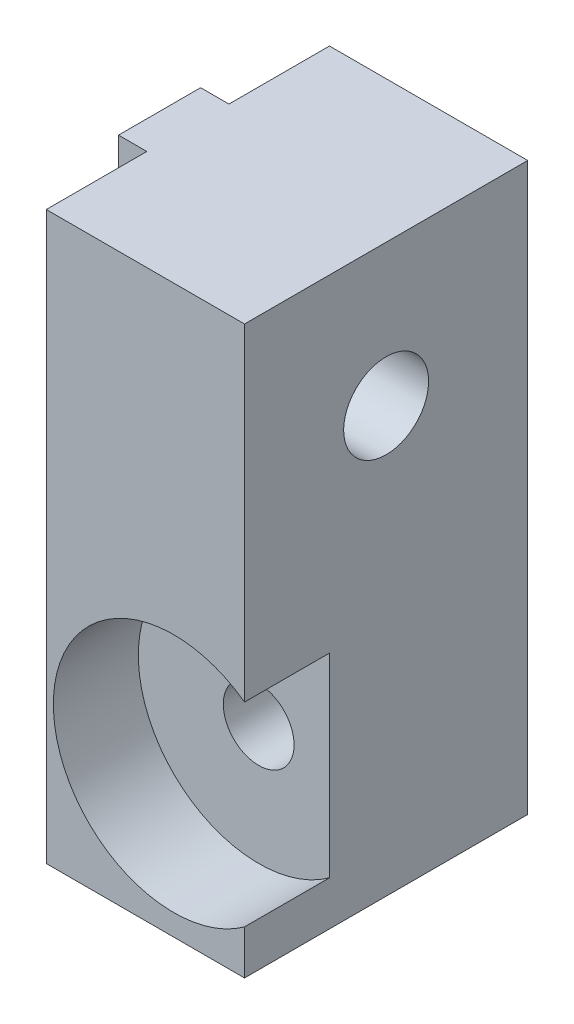
from build123d import *

# Parameters (mm, degrees)
ESQUISSE1_W                      = 7
ESQUISSE1_H                      = 20
MAIN_DEPTH                       = 10
ESQUISSE4_W                      = 2.9
ESQUISSE4_H                      = 20
MAKERBEAMFIXVERTICAL_DEPTH       = 1
ESQUISSE2_R                      = 1.5
MAKERBEAMVERTICALHOLE_DEPTH      = 2
MAKERBEAMVERTICALHOLE_DEPTH_BACK = 8
SKETCH1_R                        = 1.25
CUT_EXTRUDE1_DEPTH               = 11
SKETCH2_R                        = 4.25
CUT_EXTRUDE2_DEPTH               = 3


with BuildPart() as part:
    # Esquisse1 → Main (new body)
    with BuildSketch(Plane.XY):
        with Locations((3.5, 10)):
            Rectangle(ESQUISSE1_W, ESQUISSE1_H)
    extrude(amount=MAIN_DEPTH)

    # Esquisse4 → MakerBeamFixVertical (add)
    with BuildSketch(Plane.ZY):
        with Locations((5, 10)):
            Rectangle(ESQUISSE4_W, ESQUISSE4_H)
    extrude(amount=MAKERBEAMFIXVERTICAL_DEPTH)

    # Esquisse2 → MakerBeamVerticalHole (cut, two sides)
    with BuildSketch(Plane.ZY) as makerbeamverticalhole_sk:
        with Locations((5, 15)):
            Circle(ESQUISSE2_R)
    extrude(amount=MAKERBEAMVERTICALHOLE_DEPTH, mode=Mode.SUBTRACT)
    extrude(makerbeamverticalhole_sk.sketch, amount=-MAKERBEAMVERTICALHOLE_DEPTH_BACK, mode=Mode.SUBTRACT)

    # Sketch1 → Cut-Extrude1 (cut, through all)
    with BuildSketch(Plane.XY.offset(10)):
        with Locations((4.5, 5)):
            Circle(SKETCH1_R)
    extrude(amount=-CUT_EXTRUDE1_DEPTH, mode=Mode.SUBTRACT)

    # Sketch2 → Cut-Extrude2 (cut)
    with BuildSketch(Plane.XY.offset(10)):
        with Locations((4.5, 5)):
            Circle(SKETCH2_R)
    extrude(amount=-CUT_EXTRUDE2_DEPTH, mode=Mode.SUBTRACT)


solid = part.part
